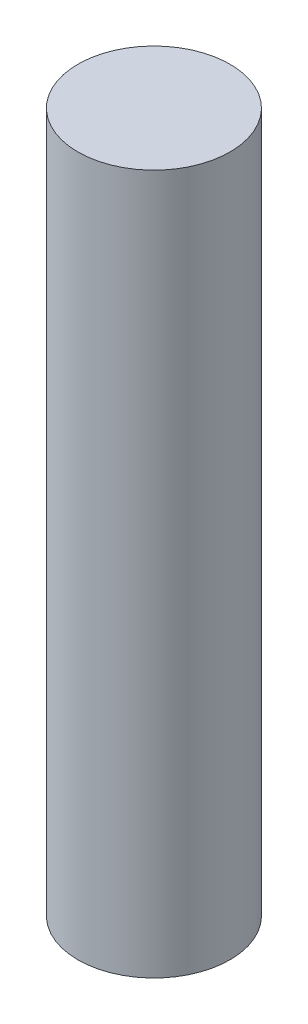
from build123d import *

# Parameters (mm, degrees)
SKETCH1_R           = 2.5
BOSS_EXTRUDE1_DEPTH = 23


with BuildPart() as part:
    # Sketch1 → Boss-Extrude1 (new body)
    with BuildSketch(Plane(origin=(0, 0, 0), x_dir=(1, 0, 0), z_dir=(0, 1, 0))):
        Circle(SKETCH1_R)
    extrude(amount=BOSS_EXTRUDE1_DEPTH)


solid = part.part
